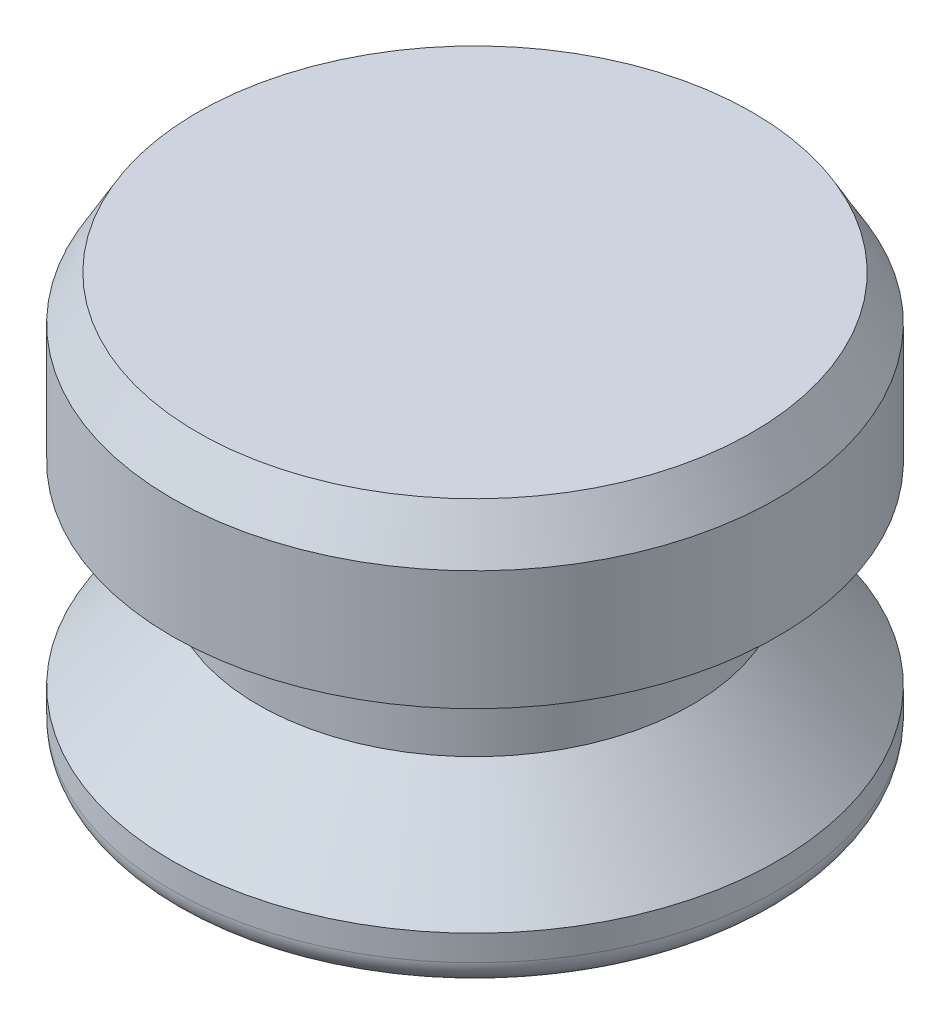
from build123d import *

# Parameters (mm, degrees)
FILLET1_R      = 0.79375
CHAMFER1_SIZE  = 0.79375
CHAMFER1_SIZE2 = 1.374815329


with BuildPart() as part:
    # Sketch1 → Revolve1 (revolve)
    with BuildSketch(Plane.XY):
        Polygon((0, 0), (-9.398, 0), (-9.398, 1.5875), (-6.731, 4.445), (-6.731, 7.62), (-9.398, 7.62), (-9.398, 12.7), (0, 12.7), align=None)
    revolve(axis=Axis((0, 0, 0), (0, 1, 0)))

    # Fillet1
    fillet1_edges = [part.edges().sort_by_distance(p)[0] for p in [
        (9.398, 0, 0),
    ]]
    fillet(fillet1_edges, radius=FILLET1_R)

    # Chamfer1
    chamfer1_edges = [part.edges().sort_by_distance(p)[0] for p in [
        (9.398, 12.7, 0),
    ]]
    chamfer1_side = [part.faces().sort_by_distance(p)[0] for p in [
        (0, 12.7, 0),
    ]]
    chamfer(chamfer1_edges, length=CHAMFER1_SIZE, length2=CHAMFER1_SIZE2, reference=chamfer1_side[0])


solid = part.part
